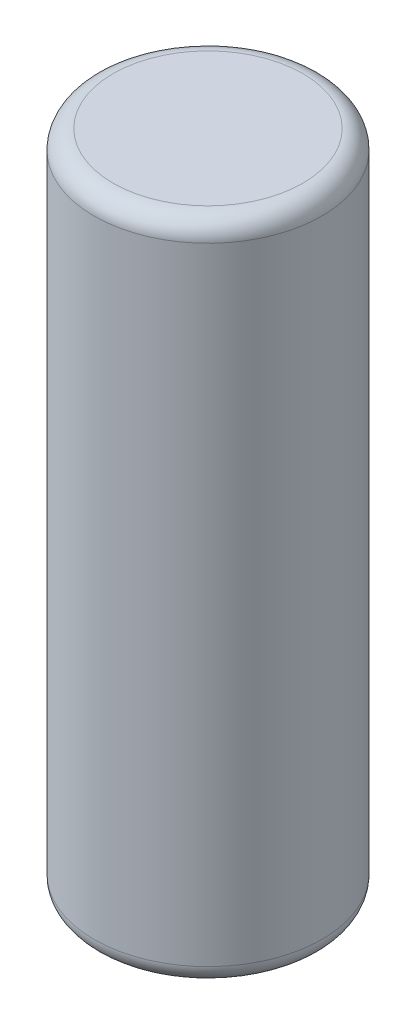
from build123d import *

# Parameters (mm, degrees)
SKETCH1_R           = 6
BOSS_EXTRUDE1_DEPTH = 35
FILLET1_R           = 1


with BuildPart() as part:
    # Sketch1 → Boss-Extrude1 (new body)
    with BuildSketch(Plane(origin=(0, 0, 0), x_dir=(1, 0, 0), z_dir=(0, 1, 0))):
        Circle(SKETCH1_R)
    extrude(amount=BOSS_EXTRUDE1_DEPTH)

    # Fillet1
    fillet1_edges = [part.edges().sort_by_distance(p)[0] for p in [
        (-6, 0, 0),
        (-6, 35, 0),
    ]]
    fillet(fillet1_edges, radius=FILLET1_R)


solid = part.part
